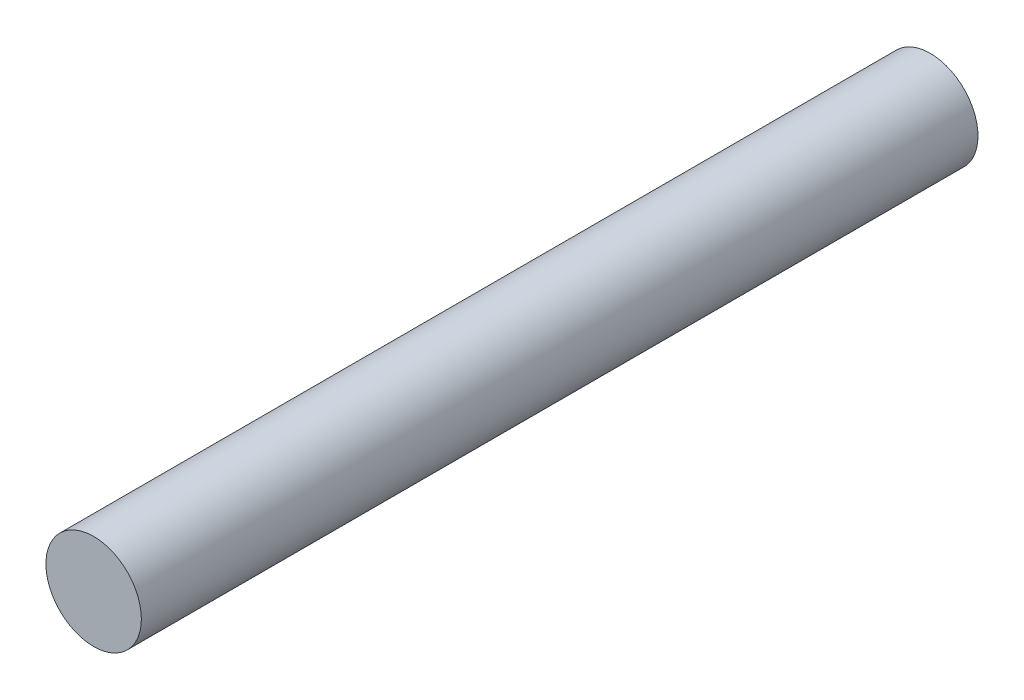
from build123d import *

# Parameters (mm, degrees)
CROQUIS1_R              = 8.5
SALIENTE_EXTRUIR1_DEPTH = 149


with BuildPart() as part:
    # Croquis1 → Saliente-Extruir1 (new body)
    with BuildSketch(Plane.XY):
        Circle(CROQUIS1_R)
    extrude(amount=SALIENTE_EXTRUIR1_DEPTH)


solid = part.part
